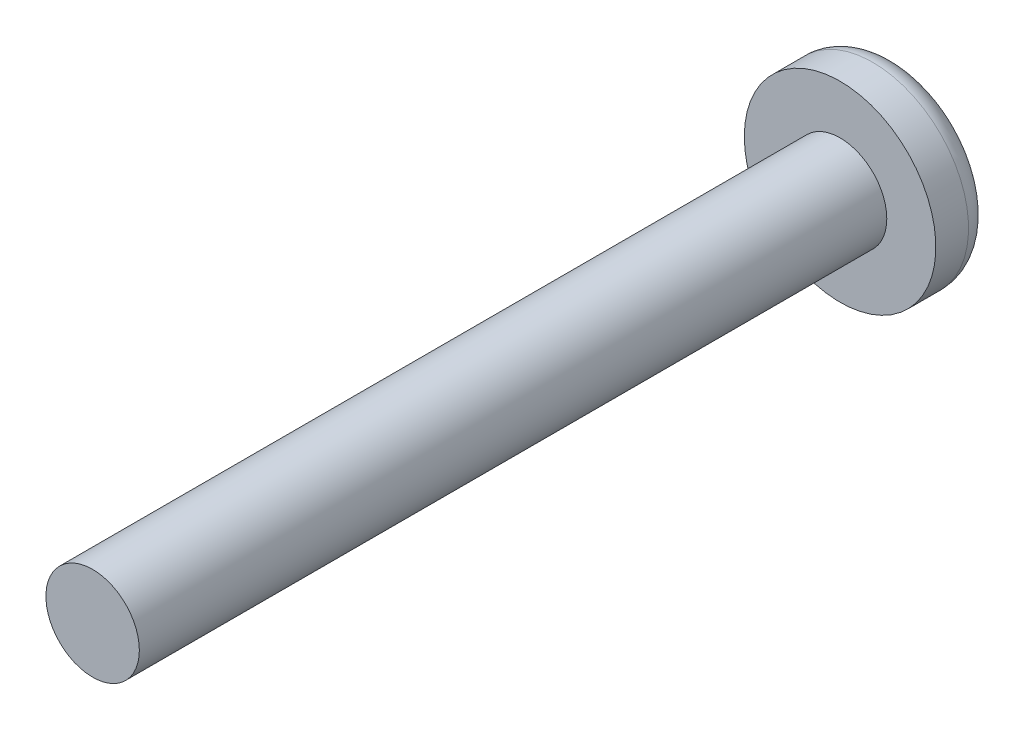
from build123d import *

# Parameters (mm, degrees)
SCHIZZO1_R                   = 1
ESTRUSIONE_ESTRUSIONE1_DEPTH = 16
SCHIZZO2_R                   = 2.05
ESTRUSIONE_ESTRUSIONE2_DEPTH = 1.2
RACCORDO1_R                  = 0.5
TAGLIO_ESTRUSIONE1_DEPTH     = 0.5


with BuildPart() as part:
    # Schizzo1 → Estrusione-Estrusione1 (new body)
    with BuildSketch(Plane.XY):
        Circle(SCHIZZO1_R)
    extrude(amount=ESTRUSIONE_ESTRUSIONE1_DEPTH)

    # Schizzo2 → Estrusione-Estrusione2 (add)
    with BuildSketch(Plane(origin=(0, 0, 0), x_dir=(-1, 0, 0), z_dir=(0, 0, -1))):
        Circle(SCHIZZO2_R)
    extrude(amount=ESTRUSIONE_ESTRUSIONE2_DEPTH)

    # Raccordo1
    raccordo1_edges = [part.edges().sort_by_distance(p)[0] for p in [
        (2.05, 0, -1.2),
    ]]
    fillet(raccordo1_edges, radius=RACCORDO1_R)

    # Schizzo3 → Taglio-Estrusione1 (cut)
    with BuildSketch(Plane(origin=(0, 0, -1.2), x_dir=(-1, 0, 0), z_dir=(0, 0, -1))):
        Polygon((-0.25, 0.25), (-1, 0.25), (-1, -0.25), (-0.25, -0.25), (-0.25, -1), (0.25, -1), (0.25, -0.25), (1, -0.25), (1, 0.25), (0.25, 0.25), (0.25, 1), (-0.25, 1), align=None)
    extrude(amount=-TAGLIO_ESTRUSIONE1_DEPTH, mode=Mode.SUBTRACT)


solid = part.part
